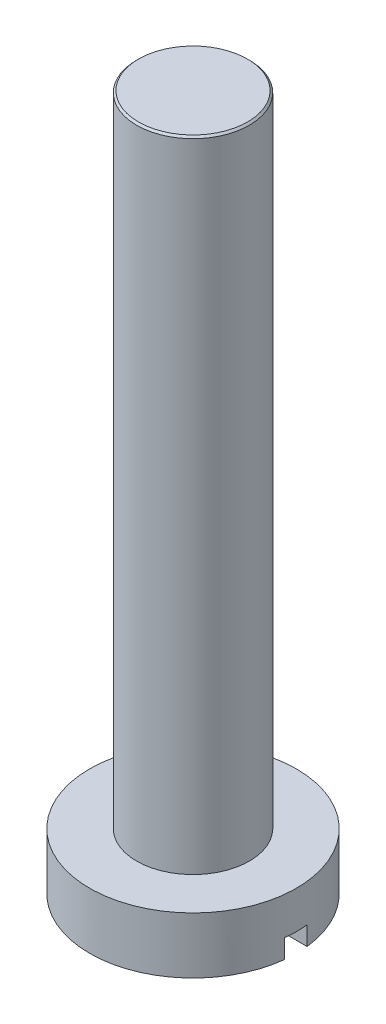
from build123d import *

# Parameters (mm, degrees)
SKETCH1_R           = 1.5
BOSS_EXTRUDE1_DEPTH = 17
SKETCH2_R           = 2.75
BOSS_EXTRUDE2_DEPTH = 1.5
SKETCH3_W           = 8.196351728
SKETCH3_H           = 0.6
CUT_EXTRUDE1_DEPTH  = 0.5
CHAMFER1_SIZE       = 0.05


with BuildPart() as part:
    # Sketch1 → Boss-Extrude1 (new body)
    with BuildSketch(Plane(origin=(0, 0, 0), x_dir=(1, 0, 0), z_dir=(0, 1, 0))):
        Circle(SKETCH1_R)
    extrude(amount=BOSS_EXTRUDE1_DEPTH)

    # Chamfer1
    chamfer1_edges = [part.edges().sort_by_distance(p)[0] for p in [
        (-1.5, 17, 0),
    ]]
    chamfer(chamfer1_edges, length=CHAMFER1_SIZE)


with BuildPart() as body_2:
    # Sketch2 → Boss-Extrude2 (new body)
    with BuildSketch(Plane.XZ):
        Circle(SKETCH2_R)
    extrude(amount=BOSS_EXTRUDE2_DEPTH)

    # Sketch3 → Cut-Extrude1 (cut)
    with BuildSketch(Plane.XZ.offset(1.5)):
        Rectangle(SKETCH3_W, SKETCH3_H)
    extrude(amount=-CUT_EXTRUDE1_DEPTH, mode=Mode.SUBTRACT)


solid = Compound([part.part, body_2.part])
